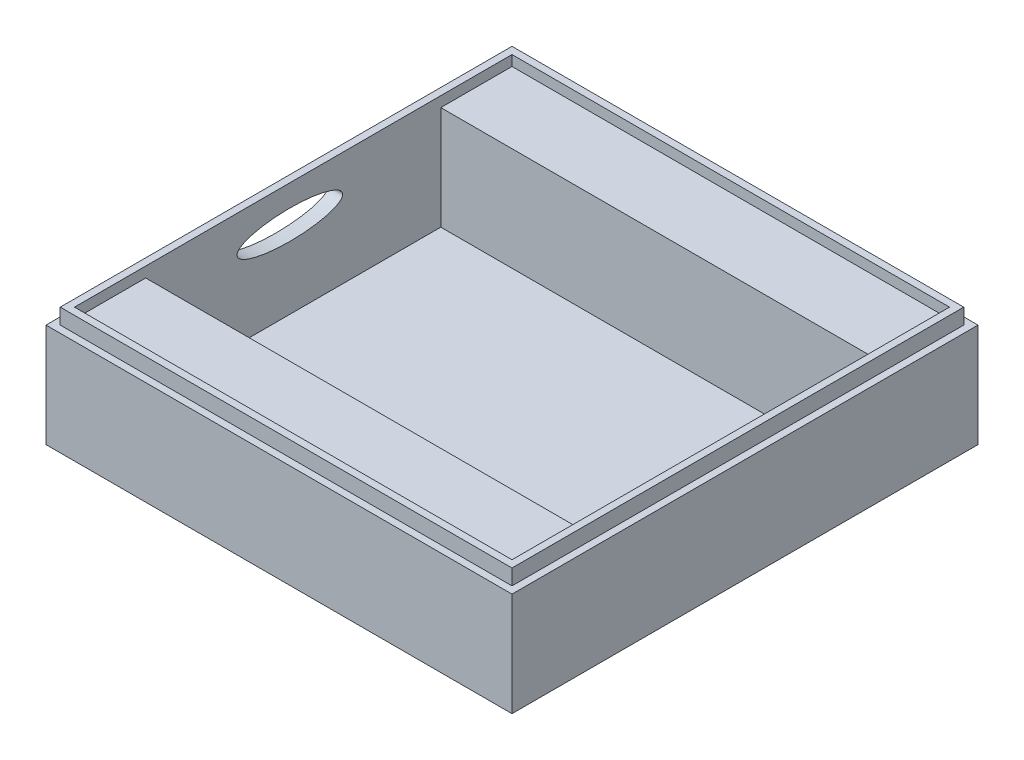
from build123d import *

# Parameters (mm, degrees)
SKETCH2_W           = 90
SKETCH2_H           = 90
BOSS_EXTRUDE1_DEPTH = 20
SKETCH5_W           = 84.5
SKETCH5_H           = 84.5
CUT_EXTRUDE2_DEPTH  = 13
SKETCH13_W          = 84.5
SKETCH13_H          = 57
CUT_EXTRUDE5_DEPTH  = 6
SKETCH17_RX         = 10.196247106
SKETCH17_RY         = 2.793572888
CUT_EXTRUDE6_DEPTH  = 2.75
SKETCH25_W          = 84.5
SKETCH25_H          = 13.75
BOSS_EXTRUDE6_DEPTH = 14
SKETCH27_W          = 87.25
SKETCH27_H          = 87.25
SKETCH27_W_2        = 84.5
SKETCH27_H_2        = 84.5
BOSS_EXTRUDE8_DEPTH = 3


with BuildPart() as part:
    # Sketch2 → Boss-Extrude1 (new body)
    with BuildSketch(Plane(origin=(0, 0, 0), x_dir=(1, 0, 0), z_dir=(0, 1, 0))):
        Rectangle(SKETCH2_W, SKETCH2_H)
    extrude(amount=BOSS_EXTRUDE1_DEPTH)

    # Sketch5 → Cut-Extrude2 (cut)
    with BuildSketch(Plane(origin=(0, 20, 0), x_dir=(1, 0, 0), z_dir=(0, 1, 0))):
        Rectangle(SKETCH5_W, SKETCH5_H)
    extrude(amount=-CUT_EXTRUDE2_DEPTH, mode=Mode.SUBTRACT)

    # Sketch13 → Cut-Extrude5 (cut)
    with BuildSketch(Plane(origin=(0, 7, 0), x_dir=(1, 0, 0), z_dir=(0, 1, 0))):
        Rectangle(SKETCH13_W, SKETCH13_H)
    extrude(amount=-CUT_EXTRUDE5_DEPTH, mode=Mode.SUBTRACT)

    # Sketch17 → Cut-Extrude6 (cut)
    with BuildSketch(Plane(origin=(-45, -8.202038474, 0), x_dir=(0, 0, 1), z_dir=(-1, 0, 0))):
        with Locations(Location((0.657720021, 24.185537931), (0, 0, 180))):
            Ellipse(SKETCH17_RX, SKETCH17_RY)
    extrude(amount=-CUT_EXTRUDE6_DEPTH, mode=Mode.SUBTRACT)

    # Sketch25 → Boss-Extrude6 (add)
    with BuildSketch(Plane(origin=(0, 7, 0), x_dir=(1, 0, 0), z_dir=(0, 1, 0))):
        with Locations((0, 35.375)):
            Rectangle(SKETCH25_W, SKETCH25_H)
        with Locations((0, -35.375)):
            Rectangle(SKETCH25_W, SKETCH25_H)
    extrude(amount=BOSS_EXTRUDE6_DEPTH)

    # Sketch27 → Boss-Extrude8 (add)
    with BuildSketch(Plane(origin=(0, 20, 0), x_dir=(1, 0, 0), z_dir=(0, 1, 0))):
        Rectangle(SKETCH27_W, SKETCH27_H)
        Rectangle(SKETCH27_W_2, SKETCH27_H_2, mode=Mode.SUBTRACT)
    extrude(amount=BOSS_EXTRUDE8_DEPTH)


solid = part.part
